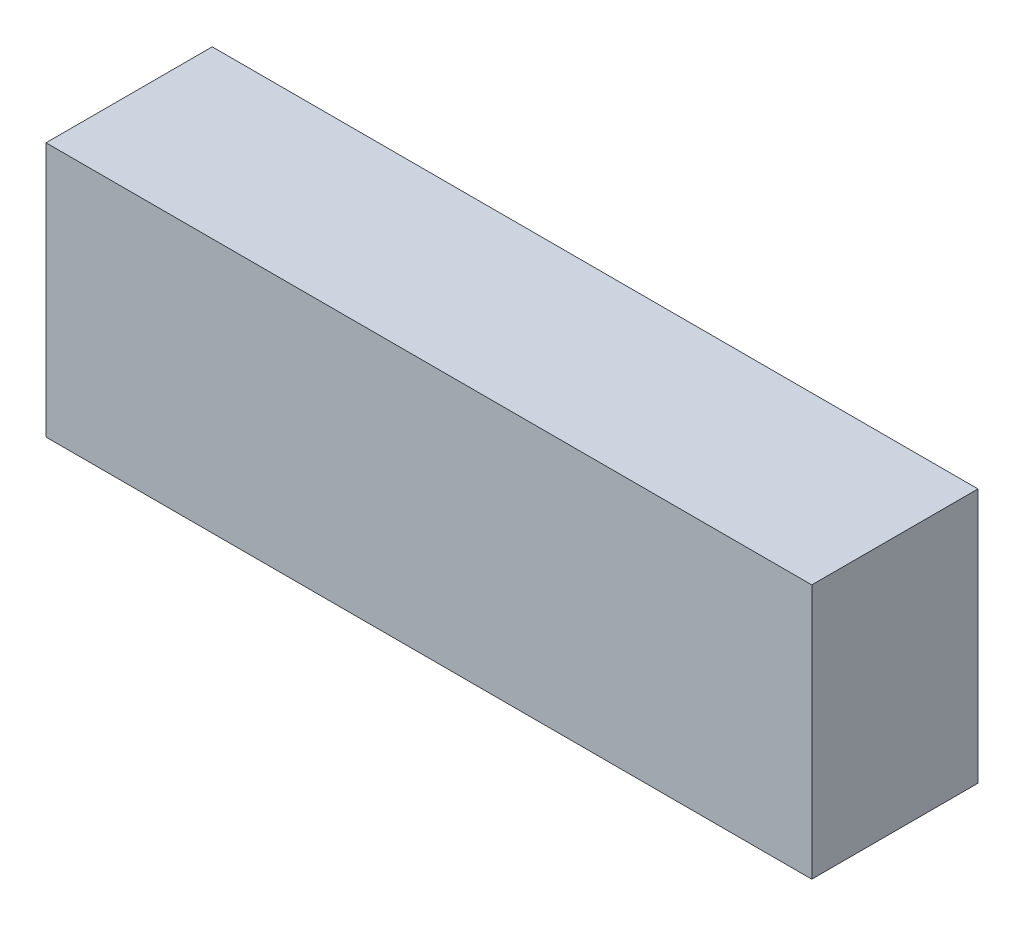
from build123d import *

# Parameters (mm, degrees)
SKETCH1_W           = 87.757
SKETCH1_H           = 29.21
BOSS_EXTRUDE1_DEPTH = 19.05


with BuildPart() as part:
    # Sketch1 → Boss-Extrude1 (new body)
    with BuildSketch(Plane.XY):
        Rectangle(SKETCH1_W, SKETCH1_H)
    extrude(amount=BOSS_EXTRUDE1_DEPTH)


solid = part.part
